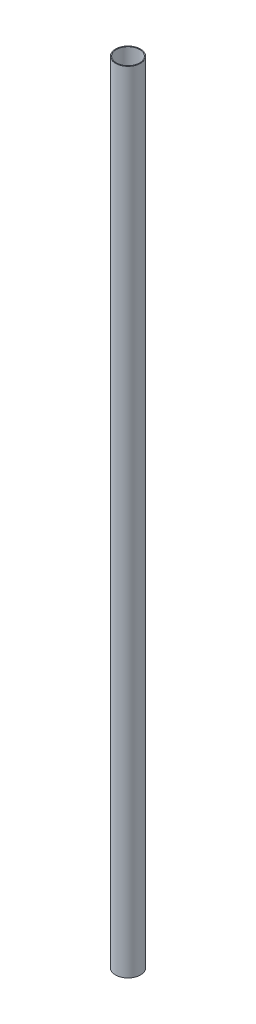
from build123d import *

# Parameters (mm, degrees)
ESQUISSE1_R        = 15
ESQUISSE1_R_2      = 14
BOSS_EXTRU_1_DEPTH = 950


with BuildPart() as part:
    # Esquisse1 → Boss.-Extru.1 (new body)
    with BuildSketch(Plane(origin=(0, 0, 0), x_dir=(1, 0, 0), z_dir=(0, 1, 0))):
        with Locations(Location((0, 0, 0), (0, 0, 270))):  # turned: the seam where the file's is
            Circle(ESQUISSE1_R)
        with Locations(Location((0, 0, 0), (0, 0, 270))):  # turned: the seam where the file's is
            Circle(ESQUISSE1_R_2, mode=Mode.SUBTRACT)
    extrude(amount=BOSS_EXTRU_1_DEPTH)


solid = part.part
